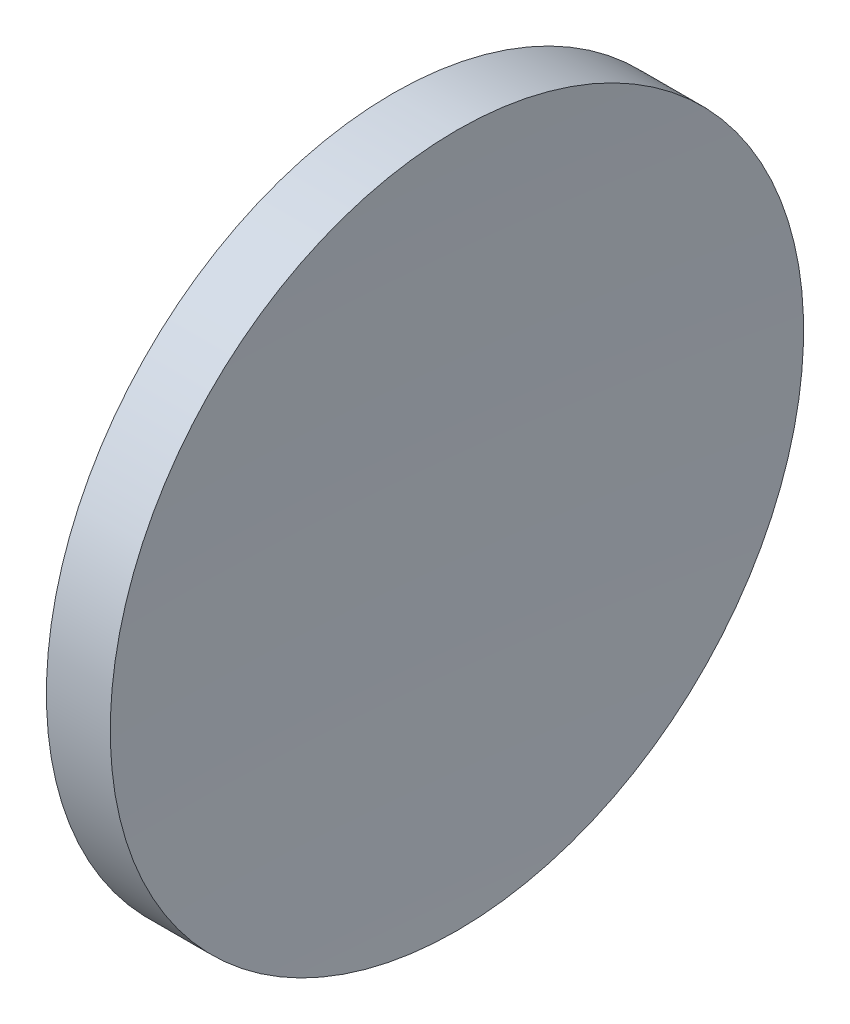
from build123d import *


with BuildPart() as part:
    # 草图1 → 旋转1 (revolve)
    with BuildSketch(Plane.XY, mode=Mode.PRIVATE) as revolve_1_sk:
        with BuildLine():
            Line((57.358190158, 32.578725913), (57.358190158, 45.078725913))
            Line((57.358190158, 45.078725913), (59.660966658, 45.078725913))
            ThreePointArc((59.660966658, 45.078725913), (59.433895382, 38.830559117), (59.358190158, 32.578725913))
            Line((59.358190158, 32.578725913), (57.358190158, 32.578725913))
        make_face()
    revolve(revolve_1_sk.sketch.rotate(Axis((55.007394624, 32.578725913, 0), (1, 0, 0)), 180), axis=Axis((55.007394624, 32.578725913, 0), (1, 0, 0)))  # turned: the seam where the file's is


solid = part.part
